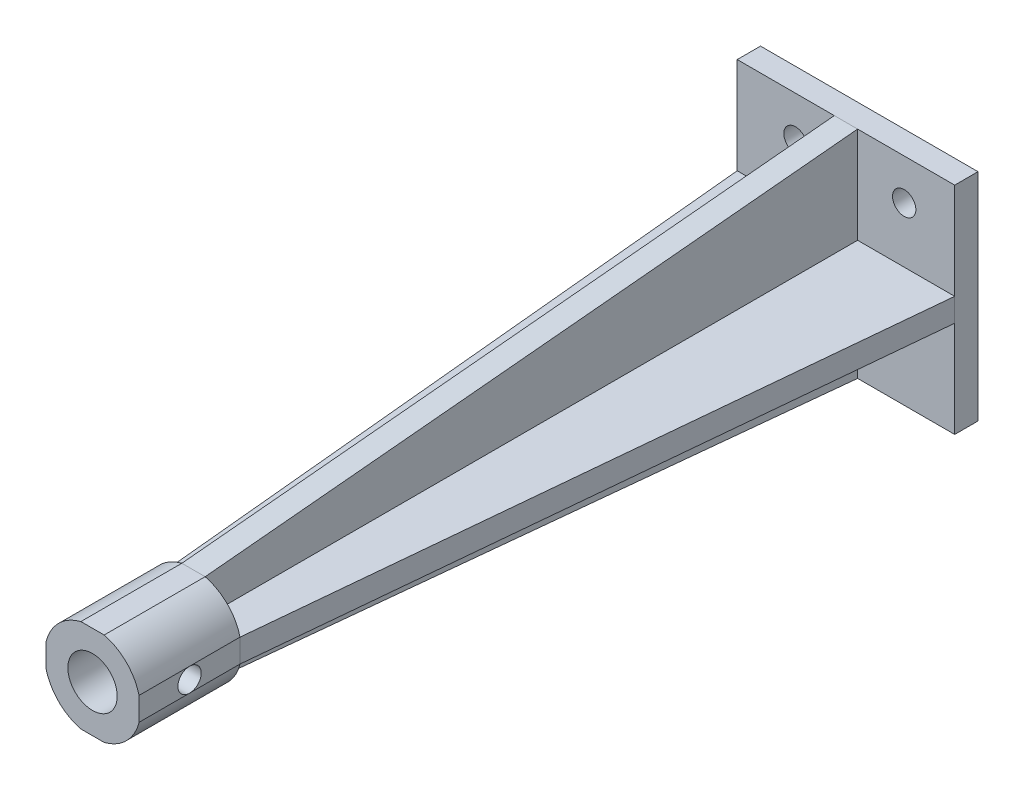
from build123d import *

# Parameters (mm, degrees)
CROQUIS1_W              = 28
CROQUIS1_H              = 27.802688173
CROQUIS1_R              = 1.5
SALIENTE_EXTRUIR1_DEPTH = 3
CROQUIS2_W              = 3
CROQUIS2_H              = 12.401344086
CROQUIS2_H_2            = 3
CROQUIS2_H_3            = 12.401344087
CROQUIS2_W_2            = 12.5
SALIENTE_EXTRUIR2_DEPTH = 100
CROQUIS3_R              = 6.175
SALIENTE_EXTRUIR3_DEPTH = 13
CORTAR_EXTRUIR6_START   = 100
CROQUIS4_R              = 3.175
CORTAR_EXTRUIR6_DEPTH   = 10
CORTAR_EXTRUIR7_START   = 10.840894
CORTAR_EXTRUIR7_DEPTH   = 3
CORTAR_EXTRUIR8_START   = -31.5
CORTAR_EXTRUIR8_DEPTH   = 3
CROQUIS14_R             = 1.5
CORTAR_EXTRUIR9_DEPTH   = 12


with BuildPart() as part:
    # Croquis1 → Saliente-Extruir1 (new body)
    with BuildSketch(Plane.XY):
        with Locations((-33, 12.340894038)):
            Rectangle(CROQUIS1_W, CROQUIS1_H)
        with Locations((-39.5, 7)):
            Circle(CROQUIS1_R, mode=Mode.SUBTRACT)
        with Locations((-39.5, 21)):
            Circle(CROQUIS1_R, mode=Mode.SUBTRACT)
        with Locations((-25.5, 21)):
            Circle(CROQUIS1_R, mode=Mode.SUBTRACT)
        with Locations((-25.5, 7)):
            Circle(CROQUIS1_R, mode=Mode.SUBTRACT)
    extrude(amount=SALIENTE_EXTRUIR1_DEPTH)

    # Croquis2 → Saliente-Extruir2 (add)
    with BuildSketch(Plane.XY):
        with Locations((-33, 4.640221994)):
            Rectangle(CROQUIS2_W, CROQUIS2_H)
        with Locations((-33, 12.340894037)):
            Rectangle(CROQUIS2_W, CROQUIS2_H_2)
        with Locations((-33, 20.041566081)):
            Rectangle(CROQUIS2_W, CROQUIS2_H_3)
        with Locations((-25.25, 12.340894037)):
            Rectangle(CROQUIS2_W_2, CROQUIS2_H_2)
        with Locations((-40.75, 12.340894037)):
            Rectangle(CROQUIS2_W_2, CROQUIS2_H_2)
    extrude(amount=SALIENTE_EXTRUIR2_DEPTH)

    # Croquis3 → Saliente-Extruir3 (add)
    with BuildSketch(Plane.XY.offset(100)):
        with Locations((-33, 12.340894037)):
            Circle(CROQUIS3_R)
    extrude(amount=-SALIENTE_EXTRUIR3_DEPTH)

    # Croquis4 → Cortar-Extruir6 (cut)
    with BuildSketch(Plane.XY.offset(CORTAR_EXTRUIR6_START)):
        with Locations((-33, 12.340894037)):
            Circle(CROQUIS4_R)
    extrude(amount=-CORTAR_EXTRUIR6_DEPTH, mode=Mode.SUBTRACT)

    # Croquis12 → Cortar-Extruir7 (cut)
    with BuildSketch(Plane(origin=(0, 0, 0), x_dir=(1, 0, 0), z_dir=(0, 1, 0)).offset(CORTAR_EXTRUIR7_START)):
        Polygon((-47, -3), (-38.990043823, -87), (-38.990043823, -100), (-47, -100), align=None)
        Polygon((-19, -3), (-19, -100), (-27.009956177, -100), (-27.009956177, -87), align=None)
    extrude(amount=CORTAR_EXTRUIR7_DEPTH, mode=Mode.SUBTRACT)

    # Croquis13 → Cortar-Extruir8 (cut)
    with BuildSketch(Plane(origin=(0, 0, 0), x_dir=(0, 0, -1), z_dir=(1, 0, 0)).offset(CORTAR_EXTRUIR8_START)):
        Polygon((-100, 18.33093786), (-87, 18.33093786), (-3, 26.242238124), (-100, 26.242238124), align=None)
        Polygon((-100, -1.560450049), (-100, 6.350850214), (-87, 6.350850214), (-3, -1.560450049), align=None)
    extrude(amount=-CORTAR_EXTRUIR8_DEPTH, mode=Mode.SUBTRACT)

    # Croquis14 → Cortar-Extruir9 (cut)
    with BuildSketch(Plane.ZY.offset(38.990043823)):
        with Locations((93.5, 12.340894037)):
            Circle(CROQUIS14_R)
    extrude(amount=-CORTAR_EXTRUIR9_DEPTH, mode=Mode.SUBTRACT)


solid = part.part
